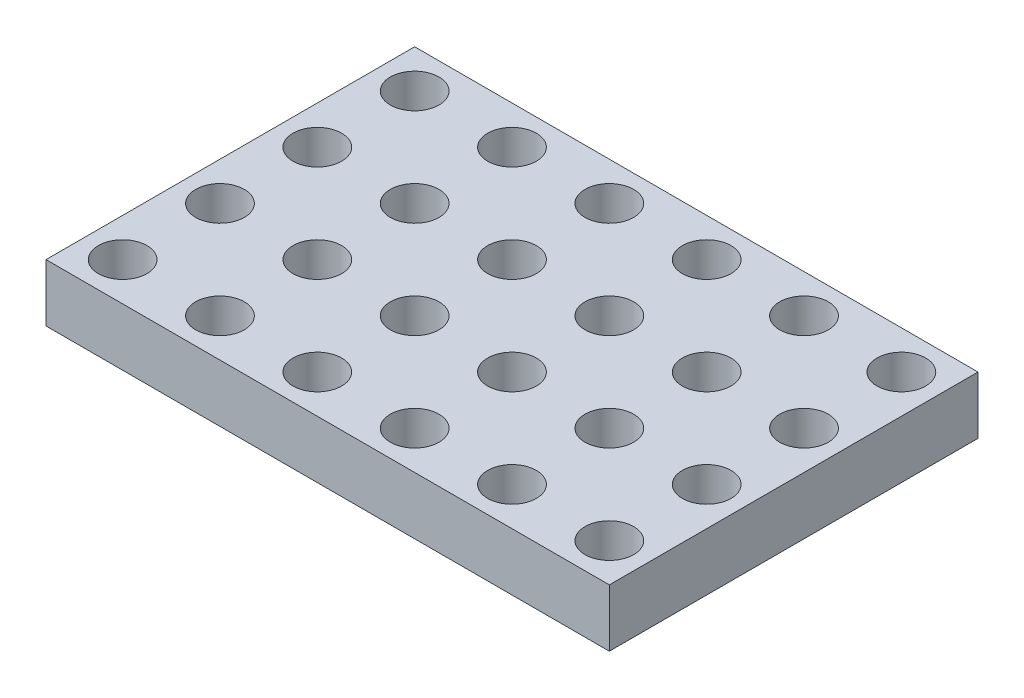
from build123d import *

# Parameters (mm, degrees)
SKETCH1_W           = 14.7
SKETCH1_H           = 9.62
SKETCH1_R           = 0.635
BOSS_EXTRUDE2_DEPTH = 1.5


with BuildPart() as part:
    # Sketch1 → Boss-Extrude2 (new body)
    with BuildSketch(Plane(origin=(0, 0, 0), x_dir=(1, 0, 0), z_dir=(0, 1, 0))):
        Rectangle(SKETCH1_W, SKETCH1_H)
        with Locations((-6.35, 3.81)):
            Circle(SKETCH1_R, mode=Mode.SUBTRACT)
        with Locations((-3.81, 3.81)):
            Circle(SKETCH1_R, mode=Mode.SUBTRACT)
        with Locations((-1.27, 3.81)):
            Circle(SKETCH1_R, mode=Mode.SUBTRACT)
        with Locations((1.27, 3.81)):
            Circle(SKETCH1_R, mode=Mode.SUBTRACT)
        with Locations((3.81, 3.81)):
            Circle(SKETCH1_R, mode=Mode.SUBTRACT)
        with Locations((6.35, 3.81)):
            Circle(SKETCH1_R, mode=Mode.SUBTRACT)
        with Locations((-6.35, 1.27)):
            Circle(SKETCH1_R, mode=Mode.SUBTRACT)
        with Locations((-3.81, 1.27)):
            Circle(SKETCH1_R, mode=Mode.SUBTRACT)
        with Locations((-1.27, 1.27)):
            Circle(SKETCH1_R, mode=Mode.SUBTRACT)
        with Locations((1.27, 1.27)):
            Circle(SKETCH1_R, mode=Mode.SUBTRACT)
        with Locations((3.81, 1.27)):
            Circle(SKETCH1_R, mode=Mode.SUBTRACT)
        with Locations((6.35, 1.27)):
            Circle(SKETCH1_R, mode=Mode.SUBTRACT)
        with Locations((-6.35, -1.27)):
            Circle(SKETCH1_R, mode=Mode.SUBTRACT)
        with Locations((-3.81, -1.27)):
            Circle(SKETCH1_R, mode=Mode.SUBTRACT)
        with Locations((-1.27, -1.27)):
            Circle(SKETCH1_R, mode=Mode.SUBTRACT)
        with Locations((1.27, -1.27)):
            Circle(SKETCH1_R, mode=Mode.SUBTRACT)
        with Locations((3.81, -1.27)):
            Circle(SKETCH1_R, mode=Mode.SUBTRACT)
        with Locations((6.35, -1.27)):
            Circle(SKETCH1_R, mode=Mode.SUBTRACT)
        with Locations((-6.35, -3.81)):
            Circle(SKETCH1_R, mode=Mode.SUBTRACT)
        with Locations((-3.81, -3.81)):
            Circle(SKETCH1_R, mode=Mode.SUBTRACT)
        with Locations((-1.27, -3.81)):
            Circle(SKETCH1_R, mode=Mode.SUBTRACT)
        with Locations((1.27, -3.81)):
            Circle(SKETCH1_R, mode=Mode.SUBTRACT)
        with Locations((3.81, -3.81)):
            Circle(SKETCH1_R, mode=Mode.SUBTRACT)
        with Locations((6.35, -3.81)):
            Circle(SKETCH1_R, mode=Mode.SUBTRACT)
    extrude(amount=BOSS_EXTRUDE2_DEPTH)


solid = part.part
